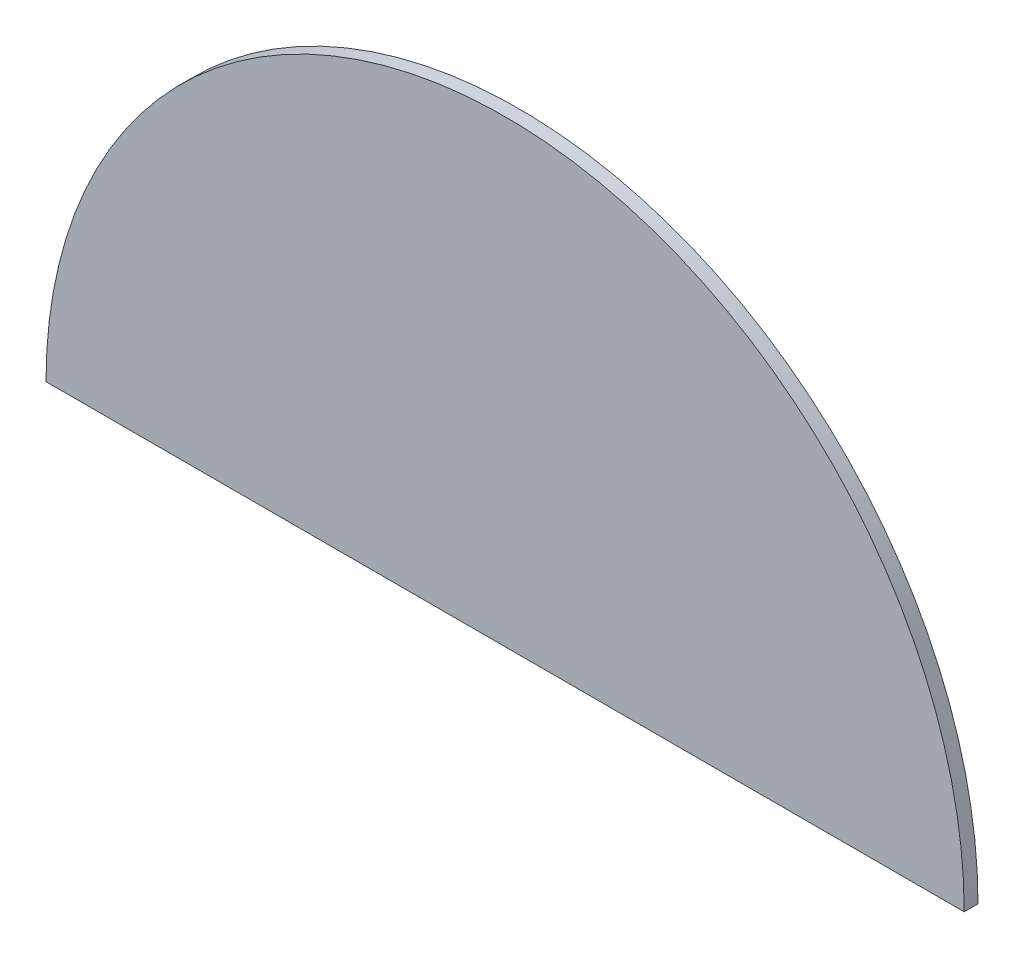
from build123d import *

# Parameters (mm, degrees)
BOSS_EXTRU_1_DEPTH = 3


with BuildPart() as part:
    # Esquisse1 → Boss.-Extru.1 (new body)
    with BuildSketch(Plane.XY):
        with BuildLine():
            Line((-100, 0), (100, 0))
            ThreePointArc((100, 0), (0, 100), (-100, 0))
        make_face()
    extrude(amount=BOSS_EXTRU_1_DEPTH)


solid = part.part
